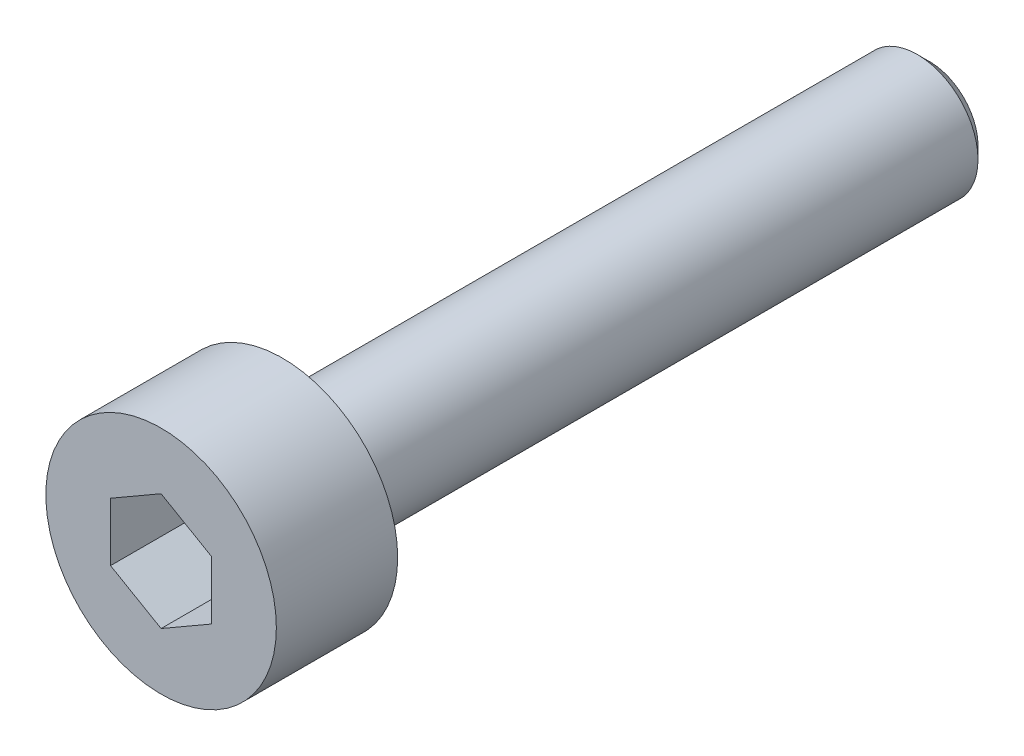
from build123d import *

# Parameters (mm, degrees)
SKETCH1_R           = 2.85
BOSS_EXTRUDE1_DEPTH = 3
SKETCH2_R           = 1.5
BOSS_EXTRUDE2_DEPTH = 16
CHAMFER1_SIZE       = 0.3
CUT_EXTRUDE1_DEPTH  = 2


with BuildPart() as part:
    # Sketch1 → Boss-Extrude1 (new body)
    with BuildSketch(Plane.XY):
        Circle(SKETCH1_R)
    extrude(amount=BOSS_EXTRUDE1_DEPTH)

    # Sketch2 → Boss-Extrude2 (add)
    with BuildSketch(Plane(origin=(0, 0, 0), x_dir=(-1, 0, 0), z_dir=(0, 0, -1))):
        Circle(SKETCH2_R)
    extrude(amount=BOSS_EXTRUDE2_DEPTH)

    # Chamfer1
    chamfer1_edges = [part.edges().sort_by_distance(p)[0] for p in [
        (1.5, 0, -16),
    ]]
    chamfer(chamfer1_edges, length=CHAMFER1_SIZE)

    # Sketch3 → Cut-Extrude1 (cut)
    with BuildSketch(Plane.XY.offset(3)):
        Polygon((0, 1.443375673), (-1.25, 0.721687836), (-1.25, -0.721687836), (0, -1.443375673), (1.25, -0.721687836), (1.25, 0.721687836), align=None)
    extrude(amount=-CUT_EXTRUDE1_DEPTH, mode=Mode.SUBTRACT)


solid = part.part
